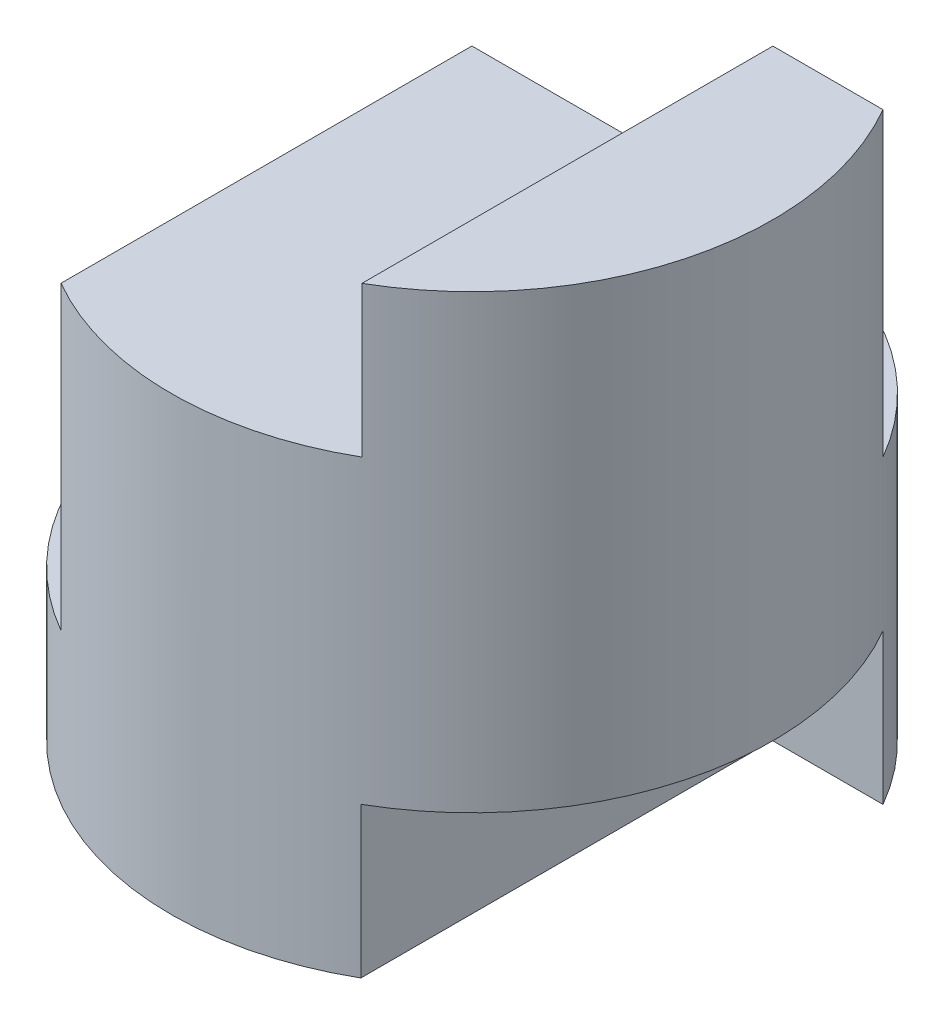
from build123d import *

# Parameters (mm, degrees)
SKETCH1_R               = 2
BOSS_EXTRUDE1_DEPTH     = 4
CUT_EXTRUDE1_DEPTH      = 2
CUT_EXTRUDE2_DEPTH      = 2
SKETCH4_W               = 0.999117212
SKETCH4_H               = 1
SKETCH4_W_2             = 1.004498255
CUT_EXTRUDE3_DEPTH      = 2
CUT_EXTRUDE3_DEPTH_BACK = 1


with BuildPart() as part:
    # Sketch1 → Boss-Extrude1 (new body)
    with BuildSketch(Plane(origin=(0, 0, 0), x_dir=(1, 0, 0), z_dir=(0, 1, 0))):
        Circle(SKETCH1_R)
    extrude(amount=BOSS_EXTRUDE1_DEPTH)

    # Sketch2 → Cut-Extrude1 (cut, symmetric)
    with BuildSketch(Plane.XY):
        Polygon((1, 4), (-2, 4), (-2, 2), (-1.000882788, 2), (-1.000882788, 3), (1, 3), align=None)
    extrude(amount=CUT_EXTRUDE1_DEPTH, both=True, mode=Mode.SUBTRACT)

    # Sketch3 → Cut-Extrude2 (cut)
    with BuildSketch(Plane(origin=(0, 4, 0), x_dir=(1, 0, 0), z_dir=(0, 1, 0))):
        with BuildLine():
            Line((-1.732050808, 1), (1.732050808, 1))
            ThreePointArc((1.732050808, 1), (0, 2), (-1.732050808, 1))
        make_face()
    extrude(amount=-CUT_EXTRUDE2_DEPTH, mode=Mode.SUBTRACT)

    # Sketch4 → Cut-Extrude3 (cut, two sides)
    with BuildSketch(Plane.XY) as cut_extrude3_sk:
        with Locations((-1.500441394, 1.5)):
            Rectangle(SKETCH4_W, SKETCH4_H)
        with Locations((1.497750873, 0.5)):
            Rectangle(SKETCH4_W_2, SKETCH4_H)
    extrude(amount=CUT_EXTRUDE3_DEPTH, mode=Mode.SUBTRACT)
    extrude(cut_extrude3_sk.sketch, amount=-CUT_EXTRUDE3_DEPTH_BACK, mode=Mode.SUBTRACT)


solid = part.part
